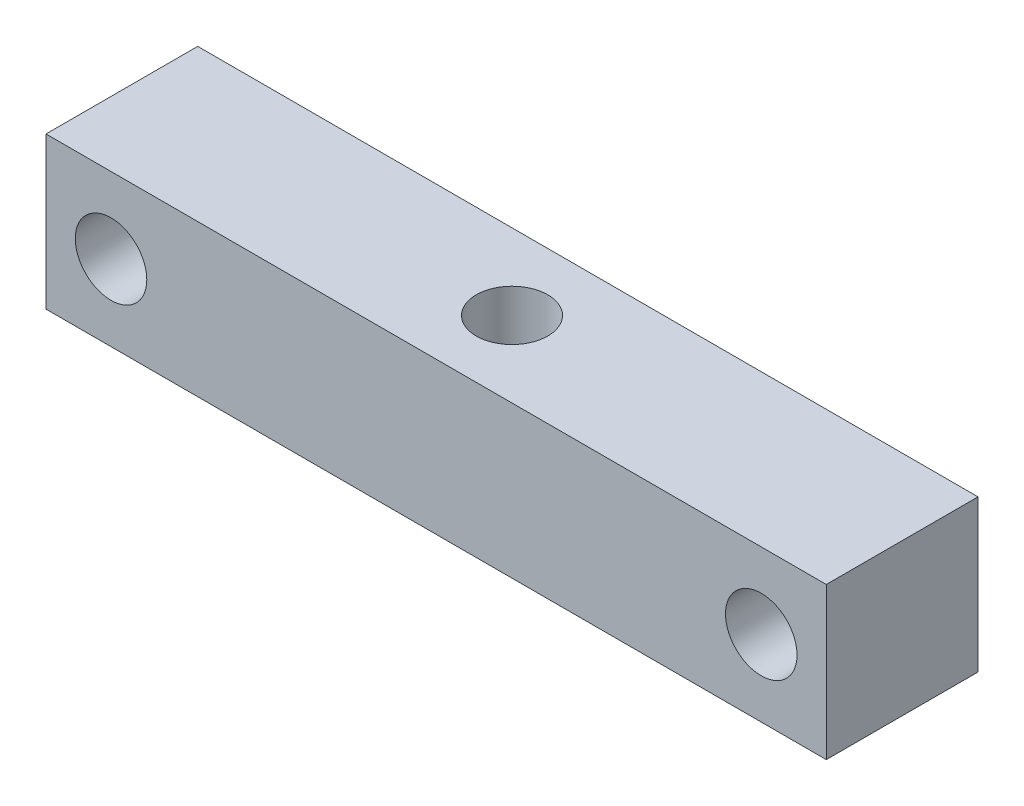
from build123d import *

# Parameters (mm, degrees)
SKETCH_1_W             = 36
SKETCH_1_H             = 7
SKETCH_1_R             = 0.5
EXTRUDE_1_DEPTH        = 3.5
HOLE_WIZARD_M4_1_D     = 3.3
HOLE_WIZARD_M4_1_DEPTH = 22.1
HOLE_WIZARD_M4_1_TIP   = 0.991420021
HOLE_WIZARD_M4_2_D     = 3.3
HOLE_WIZARD_M4_2_DEPTH = 22.1
HOLE_WIZARD_M4_2_TIP   = 0.991420021


with BuildPart() as part:
    # 草图1 → 凸台-拉伸1 (new body, symmetric)
    with BuildSketch(Plane.XY):
        Rectangle(SKETCH_1_W, SKETCH_1_H)
        with Locations((-15, 0)):
            Circle(SKETCH_1_R, mode=Mode.SUBTRACT)
        with Locations((15, 0)):
            Circle(SKETCH_1_R, mode=Mode.SUBTRACT)
    extrude(amount=EXTRUDE_1_DEPTH, both=True)

    # M4 螺纹孔1
    with Locations(Plane.XY.offset(3.5)):
        with Locations((-15, 0), (15, 0)):
            Hole(HOLE_WIZARD_M4_1_D / 2, depth=HOLE_WIZARD_M4_1_DEPTH)
            with Locations((0, 0, -(HOLE_WIZARD_M4_1_DEPTH + HOLE_WIZARD_M4_1_TIP / 2))):  # 118° drill point
                Cone(0, HOLE_WIZARD_M4_1_D / 2, HOLE_WIZARD_M4_1_TIP, mode=Mode.SUBTRACT)

    # M4 螺纹孔2
    with Locations(Plane(origin=(0, 3.5, 0), x_dir=(1, 0, 0), z_dir=(0, 1, 0))):
        with Locations((0, 0)):
            Hole(HOLE_WIZARD_M4_2_D / 2, depth=HOLE_WIZARD_M4_2_DEPTH)
            with Locations((0, 0, -(HOLE_WIZARD_M4_2_DEPTH + HOLE_WIZARD_M4_2_TIP / 2))):  # 118° drill point
                Cone(0, HOLE_WIZARD_M4_2_D / 2, HOLE_WIZARD_M4_2_TIP, mode=Mode.SUBTRACT)


solid = part.part
